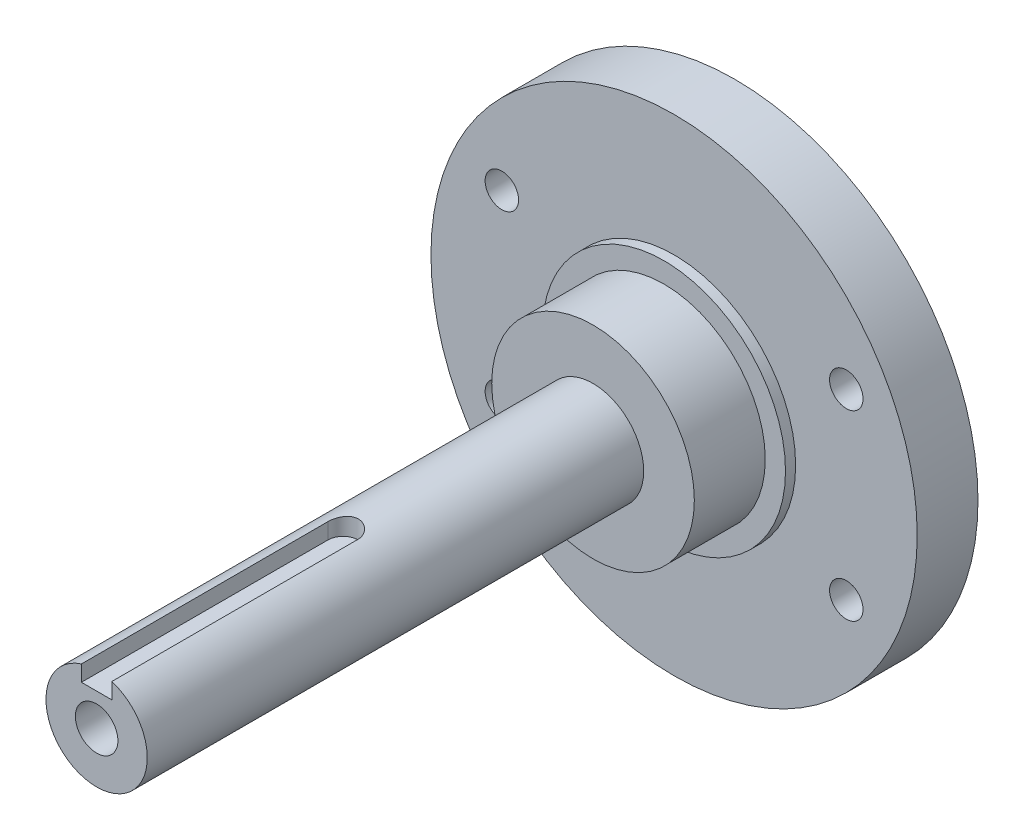
from build123d import *

# Parameters (mm, degrees)
ESQUISSE1_R                                   = 12
BOSS_EXTRU_1_DEPTH                            = 1
ESQUISSE2_R                                   = 24
BOSS_EXTRU_2_DEPTH                            = 6
TROU_POUR_TARAUDAGE_POUR_TROU_TARAUD_M4_D     = 3.3
TROU_POUR_TARAUDAGE_POUR_TROU_TARAUD_M4_DEPTH = 6
TROU_POUR_TARAUDAGE_POUR_TROU_TARAUD_M4_TIP   = 0.991420021
ESQUISSE12_R                                  = 5
BOSS_EXTRU_3_DEPTH                            = 56
TROU_POUR_TARAUDAGE_POUR_TROU_TARAUD_M5_D     = 4.2
TROU_POUR_TARAUDAGE_POUR_TROU_TARAUD_M5_DEPTH = 20
TROU_POUR_TARAUDAGE_POUR_TROU_TARAUD_M5_TIP   = 1.2618073
ENL_V_START                                   = 3.2
ENL_V_MAT_EXTRU_3_DEPTH                       = 21.8
ESQUISSE19_R                                  = 10
BOSS_EXTRU_4_DEPTH                            = 7


with BuildPart() as part:
    # Esquisse1 → Boss.-Extru.1 (new body)
    with BuildSketch(Plane.XY):
        Circle(ESQUISSE1_R)
    extrude(amount=BOSS_EXTRU_1_DEPTH)

    # Esquisse2 → Boss.-Extru.2 (add)
    with BuildSketch(Plane(origin=(0, 0, 0), x_dir=(-1, 0, 0), z_dir=(0, 0, -1))):
        Circle(ESQUISSE2_R)
    extrude(amount=BOSS_EXTRU_2_DEPTH)

    # Trou pour taraudage pour trou taraudé M42
    with Locations(Plane(origin=(0, 0, -6), x_dir=(-1, 0, 0), z_dir=(0, 0, -1))):
        with Locations((-17, 9), (17, -9), (17, 9), (-17, -9)):
            Hole(TROU_POUR_TARAUDAGE_POUR_TROU_TARAUD_M4_D / 2, depth=TROU_POUR_TARAUDAGE_POUR_TROU_TARAUD_M4_DEPTH)
            with Locations((0, 0, -(TROU_POUR_TARAUDAGE_POUR_TROU_TARAUD_M4_DEPTH + TROU_POUR_TARAUDAGE_POUR_TROU_TARAUD_M4_TIP / 2))):  # 118° drill point
                Cone(0, TROU_POUR_TARAUDAGE_POUR_TROU_TARAUD_M4_D / 2, TROU_POUR_TARAUDAGE_POUR_TROU_TARAUD_M4_TIP, mode=Mode.SUBTRACT)

    # Esquisse12 → Boss.-Extru.3 (add)
    with BuildSketch(Plane.XY.offset(1)):
        Circle(ESQUISSE12_R)
    extrude(amount=BOSS_EXTRU_3_DEPTH)

    # Trou pour taraudage pour trou taraudé M51
    with Locations(Plane.XY.offset(57)):
        with Locations((0, 0)):
            Hole(TROU_POUR_TARAUDAGE_POUR_TROU_TARAUD_M5_D / 2, depth=TROU_POUR_TARAUDAGE_POUR_TROU_TARAUD_M5_DEPTH)
            with Locations((0, 0, -(TROU_POUR_TARAUDAGE_POUR_TROU_TARAUD_M5_DEPTH + TROU_POUR_TARAUDAGE_POUR_TROU_TARAUD_M5_TIP / 2))):  # 118° drill point
                Cone(0, TROU_POUR_TARAUDAGE_POUR_TROU_TARAUD_M5_D / 2, TROU_POUR_TARAUDAGE_POUR_TROU_TARAUD_M5_TIP, mode=Mode.SUBTRACT)

    # Esquisse16 → Enlèv. mat.-Extru.3 (cut, through all)
    with BuildSketch(Plane(origin=(0, 0, 0), x_dir=(1, 0, 0), z_dir=(0, 1, 0)).offset(ENL_V_START)):
        with BuildLine():
            Line((-1.5, -57), (-1.5, -32.669951792))
            ThreePointArc((-1.5, -32.669951792), (0, -31.169951792), (1.5, -32.669951792))
            Line((1.5, -32.669951792), (1.5, -57))
            ThreePointArc((1.5, -57), (0, -58.5), (-1.5, -57))
        make_face()
    extrude(amount=ENL_V_MAT_EXTRU_3_DEPTH, mode=Mode.SUBTRACT)

    # Esquisse19 → Boss.-Extru.4 (add)
    with BuildSketch(Plane.XY.offset(1)):
        Circle(ESQUISSE19_R)
    extrude(amount=BOSS_EXTRU_4_DEPTH)


solid = part.part
